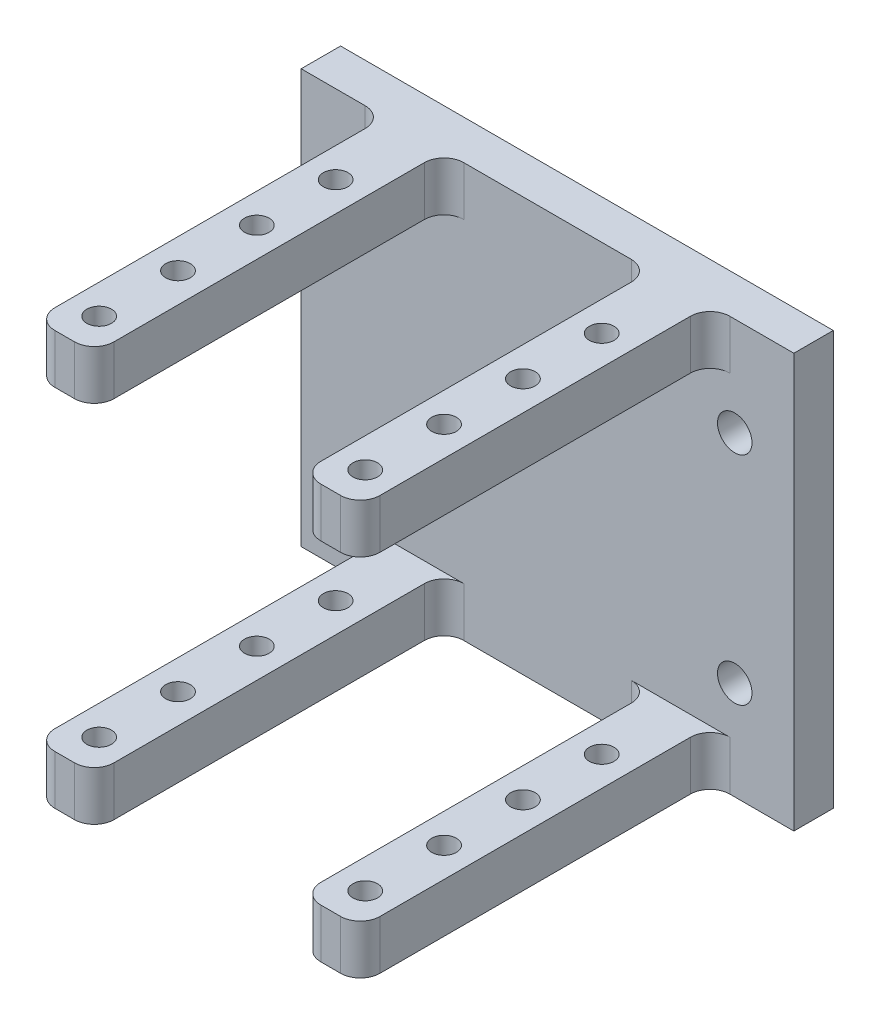
from build123d import *

# Parameters (mm, degrees)
ESQUISSE1_W             = 50
ESQUISSE1_H             = 42
ESQUISSE1_R             = 1.75
BOSS_EXTRU_1_DEPTH      = 4
ESQUISSE2_W             = 6
ESQUISSE2_H             = 5
BOSS_EXTRU_2_DEPTH      = 35.5
ESQUISSE3_R             = 1.25
ENL_V_MAT_EXTRU_1_DEPTH = 43
CONG_1_R                = 2


with BuildPart() as part:
    # Esquisse1 → Boss.-Extru.1 (new body)
    with BuildSketch(Plane.XY):
        Rectangle(ESQUISSE1_W, ESQUISSE1_H)
        with Locations((-19, 11)):
            Circle(ESQUISSE1_R, mode=Mode.SUBTRACT)
        with Locations((19, 11)):
            Circle(ESQUISSE1_R, mode=Mode.SUBTRACT)
        with Locations((19, -11)):
            Circle(ESQUISSE1_R, mode=Mode.SUBTRACT)
        with Locations((-19, -11)):
            Circle(ESQUISSE1_R, mode=Mode.SUBTRACT)
    extrude(amount=BOSS_EXTRU_1_DEPTH)

    # Esquisse2 → Boss.-Extru.2 (add)
    with BuildSketch(Plane.XY.offset(4)):
        with Locations((-13.5, 18.5)):
            Rectangle(ESQUISSE2_W, ESQUISSE2_H)
        with Locations((13.5, 18.5)):
            Rectangle(ESQUISSE2_W, ESQUISSE2_H)
        with Locations((-13.5, -18.5)):
            Rectangle(ESQUISSE2_W, ESQUISSE2_H)
        with Locations((13.5, -18.5)):
            Rectangle(ESQUISSE2_W, ESQUISSE2_H)
    extrude(amount=BOSS_EXTRU_2_DEPTH)

    # Esquisse3 → Enlèv. mat.-Extru.1 (cut, through all)
    with BuildSketch(Plane(origin=(0, 21, 0), x_dir=(1, 0, 0), z_dir=(0, 1, 0))):
        with Locations((-13.5, -12)):
            Circle(ESQUISSE3_R)
        with Locations((-13.5, -20)):
            Circle(ESQUISSE3_R)
        with Locations((-13.5, -28)):
            Circle(ESQUISSE3_R)
        with Locations((-13.5, -36)):
            Circle(ESQUISSE3_R)
        with Locations((13.5, -36)):
            Circle(ESQUISSE3_R)
        with Locations((13.5, -28)):
            Circle(ESQUISSE3_R)
        with Locations((13.5, -20)):
            Circle(ESQUISSE3_R)
        with Locations((13.5, -12)):
            Circle(ESQUISSE3_R)
    extrude(amount=-ENL_V_MAT_EXTRU_1_DEPTH, mode=Mode.SUBTRACT)

    # Congé1
    cong_1_edges = [part.edges().sort_by_distance(p)[0] for p in [
        (-16.5, 18.5, 4),
        (-10.5, 18.5, 4),
        (-16.5, 18.5, 39.5),
        (-10.5, 18.5, 39.5),
        (16.5, 18.5, 4),
        (10.5, 18.5, 4),
        (16.5, 18.5, 39.5),
        (10.5, 18.5, 39.5),
        (-10.5, -18.5, 4),
        (-16.5, -18.5, 4),
        (-10.5, -18.5, 39.5),
        (-16.5, -18.5, 39.5),
        (16.5, -18.5, 4),
        (10.5, -18.5, 4),
        (16.5, -18.5, 39.5),
        (10.5, -18.5, 39.5),
    ]]
    fillet(cong_1_edges, radius=CONG_1_R)


solid = part.part
